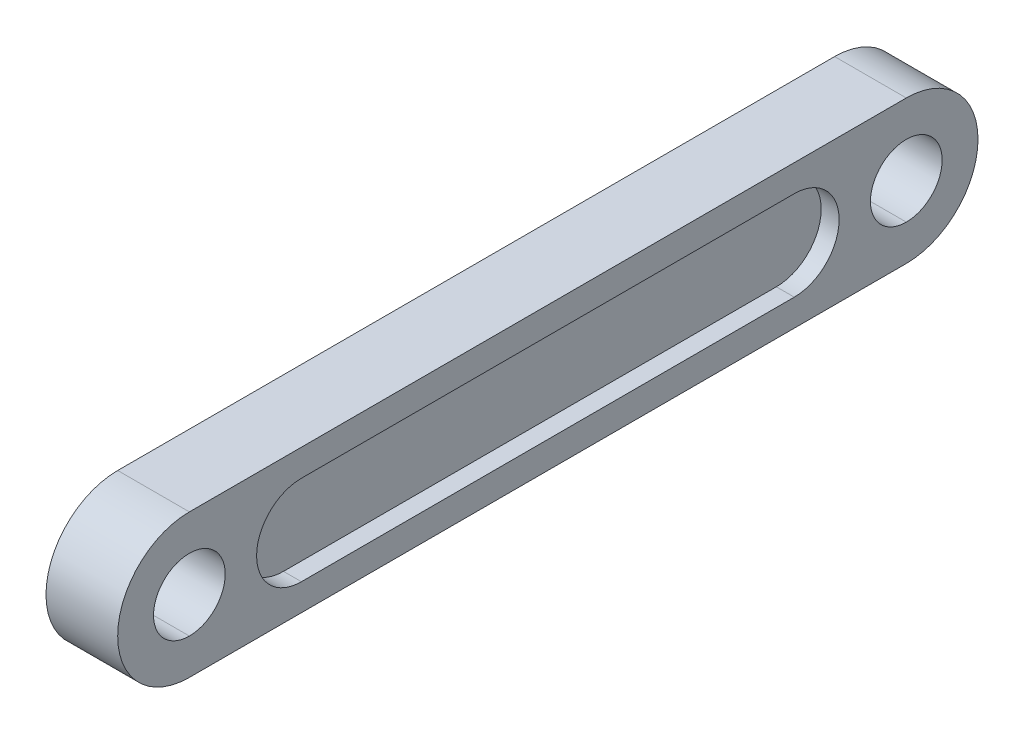
from build123d import *

# Parameters (mm, degrees)
SKETCH_1_R          = 4
EXTRUDE_1_DEPTH     = 4
CUT_EXTRUDE_1_DEPTH = 2


with BuildPart() as part:
    # 草图1 → 凸台-拉伸1 (new body, symmetric)
    with BuildSketch(Plane(origin=(0, 0, 0), x_dir=(0, 0, -1), z_dir=(1, 0, 0))):
        with BuildLine():
            Line((-40, 8), (40, 8))
            ThreePointArc((40, 8), (48, 0), (40, -8))
            Line((40, -8), (-40, -8))
            ThreePointArc((-40, -8), (-48, 0), (-40, 8))
        make_face()
        with Locations((40, 0)):
            Circle(SKETCH_1_R, mode=Mode.SUBTRACT)
        with Locations((-40, 0)):
            Circle(SKETCH_1_R, mode=Mode.SUBTRACT)
    extrude(amount=EXTRUDE_1_DEPTH, both=True)

    # 草图7 → 切除-拉伸1 (cut)
    with BuildSketch(Plane.ZY.offset(4)):
        with BuildLine():
            Line((-27.5, 5), (27.5, 5))
            ThreePointArc((27.5, 5), (32.5, 0), (27.5, -5))
            Line((27.5, -5), (-27.5, -5))
            ThreePointArc((-27.5, -5), (-32.5, 0), (-27.5, 5))
        make_face()
    cut_extrude_1 = extrude(amount=-CUT_EXTRUDE_1_DEPTH, mode=Mode.SUBTRACT)

    # 镜向1: 切除-拉伸1 across plane
    add(cut_extrude_1.mirror(Plane(origin=(0, 0, 0), x_dir=(0, 0, 1), z_dir=(1, 0, 0))), mode=Mode.SUBTRACT)


solid = part.part
